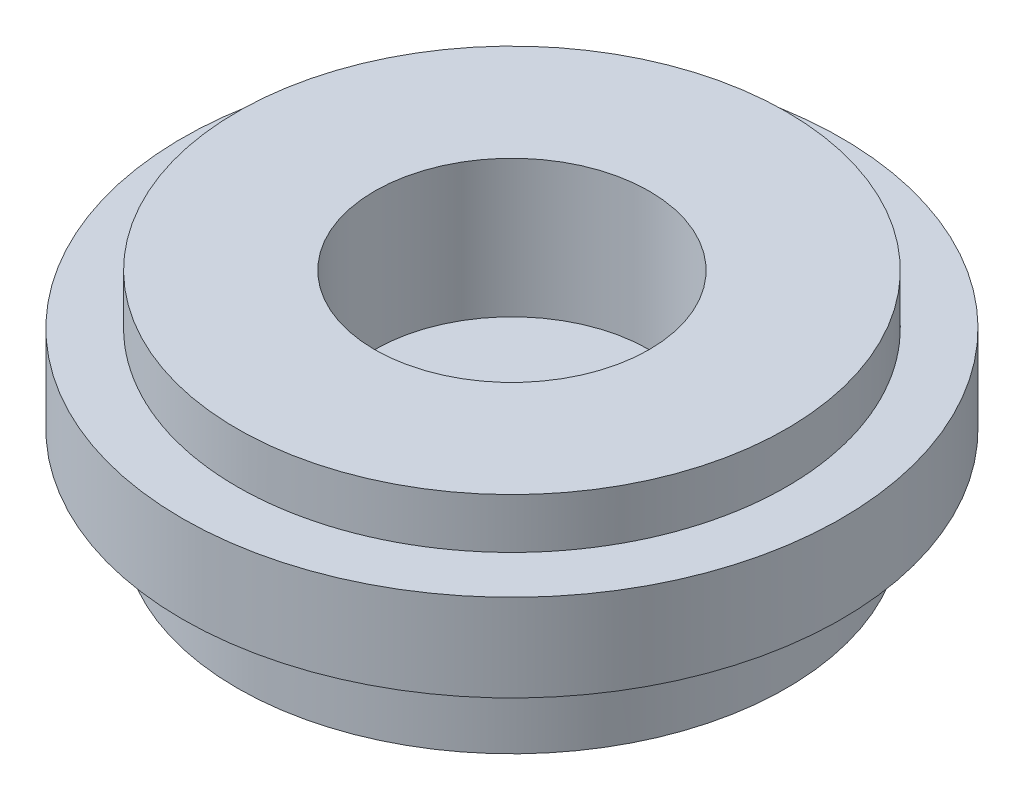
from build123d import *

# Parameters (mm, degrees)
SKETCH1_R           = 5
BOSS_EXTRUDE1_DEPTH = 1.5875
SKETCH4_R           = 6
SKETCH4_R_2         = 5
BOSS_EXTRUDE4_DEPTH = 1.5875
SKETCH2_R           = 5
SKETCH2_R_2         = 2.5
BOSS_EXTRUDE2_DEPTH = 2.5


with BuildPart() as part:
    # Sketch1 → Boss-Extrude1 (new body)
    with BuildSketch(Plane(origin=(0, 0, 0), x_dir=(1, 0, 0), z_dir=(0, 1, 0))):
        Circle(SKETCH1_R)
    extrude(amount=BOSS_EXTRUDE1_DEPTH)

    # Sketch2 → Boss-Extrude2 (add)
    with BuildSketch(Plane(origin=(0, 1.5875, 0), x_dir=(1, 0, 0), z_dir=(0, 1, 0))):
        Circle(SKETCH2_R)
        Circle(SKETCH2_R_2, mode=Mode.SUBTRACT)
    extrude(amount=BOSS_EXTRUDE2_DEPTH)


with BuildPart() as body_2:
    # Sketch4 → Boss-Extrude4 (new body)
    with BuildSketch(Plane(origin=(0, 1.5875, 0), x_dir=(1, 0, 0), z_dir=(0, 1, 0))):
        Circle(SKETCH4_R)
        Circle(SKETCH4_R_2, mode=Mode.SUBTRACT)
    extrude(amount=BOSS_EXTRUDE4_DEPTH)


solid = Compound([part.part, body_2.part])
